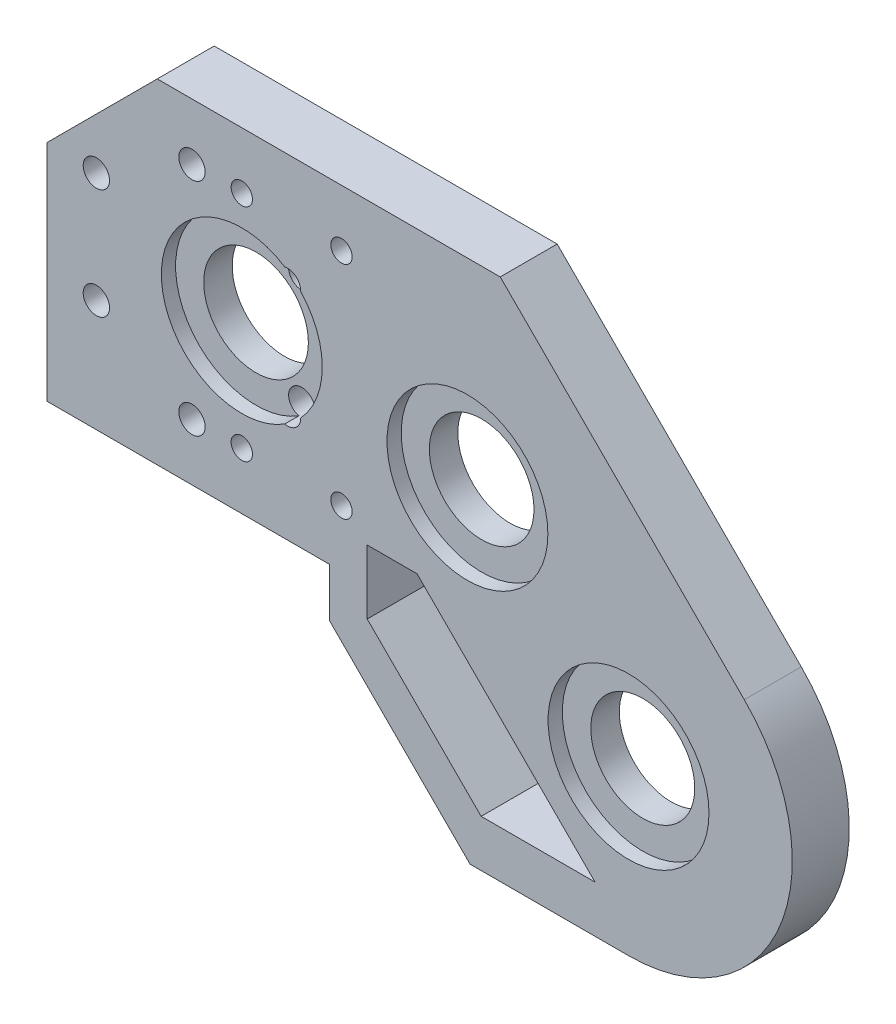
from build123d import *

# Parameters (mm, degrees)
MODEL_R                  = 7.35
MODEL_R_2                = 7.3
MODEL_R_3                = 1.85
RESSALTO_EXTRUS_O1_DEPTH = 8
ESBO_O3_R                = 11.3
CORTE_EXTRUS_O1_DEPTH    = 2
ESBO_O4_R                = 11.3
CORTE_EXTRUS_O2_DEPTH    = 2
ESBO_O2_R                = 3.3
CORTE_EXTRUS_O4_DEPTH    = 2
ESBO_O6_R                = 1.5
CORTE_EXTRUS_O5_DEPTH    = 10
ESBO_O7_R                = 1.5
SUPOERTE_PLACA_DEPTH     = 9


with BuildPart() as part:
    # Model → Ressalto-extrusão1 (new body)
    with BuildSketch(Plane.XY):
        with BuildLine():
            Line((0, 0), (39, 0))
            Line((39, 0), (39.7, 0))
            Line((39.7, 0), (39.7, -6.854833996))
            Line((39.7, -6.854833996), (52.445166004, -19.6))
            Line((52.445166004, -19.6), (59.445166004, -26.6))
            Line((59.445166004, -26.6), (81.699998871, -26.6))
            ThreePointArc((81.699998871, -26.6), (102.949229032, -12.401719466), (97.963455967, 12.663455967))
            Line((97.963455967, 12.663455967), (63.677897161, 46.949014774))
            Line((63.677897161, 46.949014774), (50.111140335, 46.949014774))
            Line((50.111140335, 46.949014774), (15.50707852, 46.949014774))
            Line((15.50707852, 46.949014774), (0, 31.441936254))
            Line((0, 31.441936254), (0, 0))
        make_face()
        with Locations((59.072583002, 19.027416998)):
            Circle(MODEL_R, mode=Mode.SUBTRACT)
        with Locations((81.7, -3.6)):
            Circle(MODEL_R_2, mode=Mode.SUBTRACT)
        with Locations((6.960594046, 15.730973227)):
            Circle(MODEL_R_3, mode=Mode.SUBTRACT)
        with Locations((6.960594046, 31.230973227)):
            Circle(MODEL_R_3, mode=Mode.SUBTRACT)
        with Locations((20.383987804, 38.980973227)):
            Circle(MODEL_R_3, mode=Mode.SUBTRACT)
        with Locations((33.807381563, 31.230973227)):
            Circle(MODEL_R_3, mode=Mode.SUBTRACT)
        with Locations((33.807381563, 15.730973227)):
            Circle(MODEL_R_3, mode=Mode.SUBTRACT)
        with Locations((20.383987804, 7.980973227)):
            Circle(MODEL_R_3, mode=Mode.SUBTRACT)
        with Locations((27.383987804, 23.480973227)):
            Circle(MODEL_R, mode=Mode.SUBTRACT)
        Polygon((72, -15), (52, 5), (45, 5), (45, -4), (61, -20), (77, -20), align=None, mode=Mode.SUBTRACT)
    extrude(amount=RESSALTO_EXTRUS_O1_DEPTH)

    # Esboço3 → Corte-extrusão1 (cut)
    with BuildSketch(Plane.XY):
        with Locations((81.7, -3.6)):
            Circle(ESBO_O3_R)
        with Locations((59.0726, 19.0274)):
            Circle(ESBO_O3_R)
        with Locations((27.384004802, 23.480956229)):
            Circle(ESBO_O3_R)
    extrude(amount=CORTE_EXTRUS_O1_DEPTH, mode=Mode.SUBTRACT)

    # Esboço4 → Corte-extrusão2 (cut)
    with BuildSketch(Plane.XY.offset(8)):
        with Locations((81.7, -3.6)):
            Circle(ESBO_O4_R)
        with Locations((59.0726, 19.0274)):
            Circle(ESBO_O4_R)
        with Locations((27.384004802, 23.480956229)):
            Circle(ESBO_O4_R)
    extrude(amount=-CORTE_EXTRUS_O2_DEPTH, mode=Mode.SUBTRACT)

    # Esboço2 → Corte-extrusão4 (cut)
    with BuildSketch(Plane.XY):
        with Locations((6.960594802, 15.730956229)):
            Circle(ESBO_O2_R)
        with Locations((6.960594802, 31.230956229)):
            Circle(ESBO_O2_R)
        with Locations((33.807404802, 15.730956229)):
            Circle(ESBO_O2_R)
        with Locations((20.384004802, 38.980956229)):
            Circle(ESBO_O2_R)
        with Locations((33.807404802, 31.230956229)):
            Circle(ESBO_O2_R)
        with Locations((20.384004802, 7.980976229)):
            Circle(ESBO_O2_R)
    extrude(amount=CORTE_EXTRUS_O4_DEPTH, mode=Mode.SUBTRACT)

    # Esboço6 → Corte-extrusão5 (cut)
    with BuildSketch(Plane.XZ):
        with Locations((11.8, 4)):
            Circle(ESBO_O6_R)
        with Locations((30.8, 4)):
            Circle(ESBO_O6_R)
    extrude(amount=-CORTE_EXTRUS_O5_DEPTH, mode=Mode.SUBTRACT)

    # Esboço7 → supoerte_placa (cut, through all)
    with BuildSketch(Plane.XY.offset(8)):
        with Locations((27.383987804, 38.980973227)):
            Circle(ESBO_O7_R)
        with Locations((41.383987804, 38.980973227)):
            Circle(ESBO_O7_R)
        with Locations((41.383987804, 7.980973227)):
            Circle(ESBO_O7_R)
        with Locations((27.383987804, 7.980973227)):
            Circle(ESBO_O7_R)
    extrude(amount=-SUPOERTE_PLACA_DEPTH, mode=Mode.SUBTRACT)


solid = part.part
